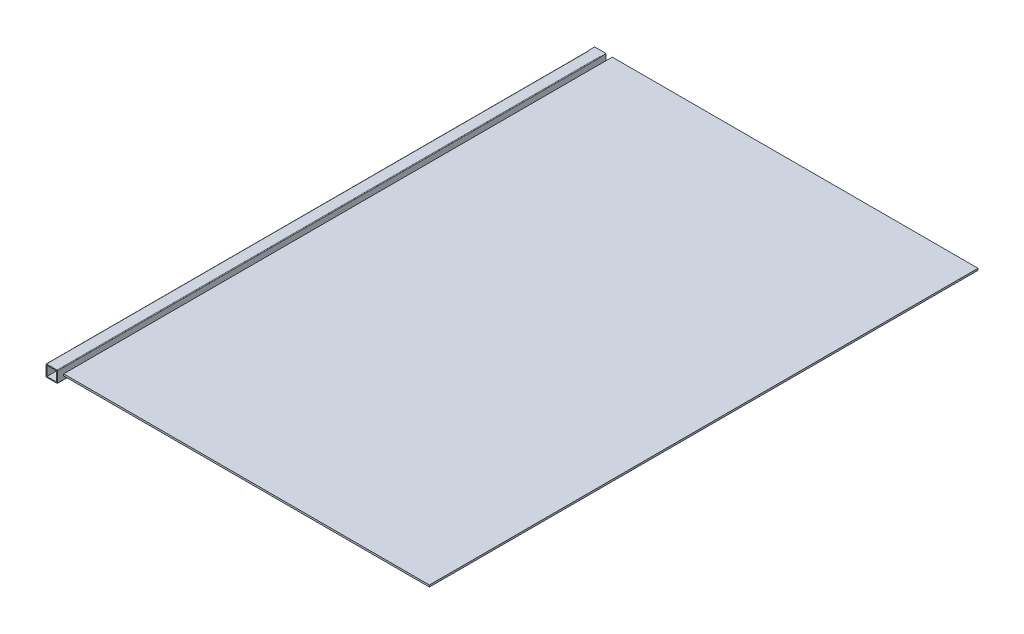
from build123d import *

# Parameters (mm, degrees)
SKETCH_1_W        = 19
SKETCH_1_H        = 19
SKETCH_1_W_2      = 15.88
SKETCH_1_H_2      = 15.88
EXTRUDE_1_DEPTH   = 900
SKETCH_1_W_3      = 600
SKETCH_1_H_3      = 3
EXTRUDE_1_2_DEPTH = 900
FILLET_2_R        = 1
SKETCH_1_2_W      = 19
SKETCH_1_2_H      = 19
SKETCH_1_2_W_2    = 15.88
SKETCH_1_2_H_2    = 15.88
SKETCH_1_2_W_3    = 600
SKETCH_1_2_H_3    = 3
EXTRUDE_2_DEPTH   = 10


with BuildPart() as part:
    # 스케치1 → 보스-돌출1 (new body)
    with BuildSketch(Plane.XY):
        with Locations((9.5, -9.5)):
            Rectangle(SKETCH_1_W, SKETCH_1_H)
        with Locations((9.5, -9.5)):
            Rectangle(SKETCH_1_W_2, SKETCH_1_H_2, mode=Mode.SUBTRACT)
    extrude(amount=EXTRUDE_1_DEPTH)

    # 필렛2
    fillet_2_edges = [part.edges().sort_by_distance(p)[0] for p in [
        (0, -19, 450),
        (0, 0, 450),
        (19, -19, 450),
        (19, 0, 450),
    ]]
    fillet(fillet_2_edges, radius=FILLET_2_R)



with BuildPart() as body_2:
    # 스케치1 → Extrude 1 2 (new body)
    with BuildSketch(Plane.XY):
        with Locations((329, -1.5)):
            Rectangle(SKETCH_1_W_3, SKETCH_1_H_3)
    extrude(amount=EXTRUDE_1_2_DEPTH)


with BuildPart() as part_1:
    add(part.part)

    add(body_2.part)  # 보스-돌출2 merges body 2
    # 스케치1<2> → 보스-돌출2 (add)
    # profile 1 of 2: a face of its own
    with BuildSketch(Plane.XY):
        with Locations((9.5, -9.5)):
            Rectangle(SKETCH_1_2_W, SKETCH_1_2_H)
        with Locations((9.5, -9.5)):
            Rectangle(SKETCH_1_2_W_2, SKETCH_1_2_H_2, mode=Mode.SUBTRACT)
    # profile 2 of 2: a face of its own
    with BuildSketch(Plane.XY):
        with Locations((329, -1.5)):
            Rectangle(SKETCH_1_2_W_3, SKETCH_1_2_H_3)
    extrude(amount=EXTRUDE_2_DEPTH)


solid = part_1.part
